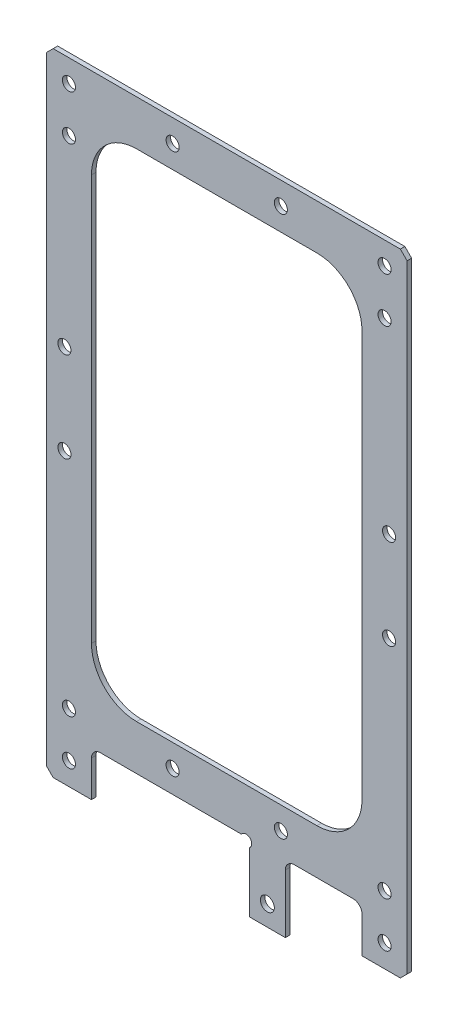
from build123d import *

# Parameters (mm, degrees)
BOSS_EXTRUDE12_DEPTH       = 1
SKETCH88_W                 = 60
SKETCH88_H                 = 110
CUT_EXTRUDE1_DEPTH         = 1
FILLET1_R                  = 10
M2_5_CLEARANCE_HOLE1_D     = 2.9
M2_5_CLEARANCE_HOLE1_DEPTH = 11.5
SKETCH91_W                 = 8
SKETCH91_H                 = 15
SKETCH91_R                 = 1.55
BOSS_EXTRUDE13_DEPTH       = 1
FILLET2_R                  = 2
CHAMFER1_SIZE              = 1.5
SKETCH93_R                 = 1.25
CUT_EXTRUDE2_DEPTH         = 10
M2_5_CLEARANCE_HOLE2_D     = 2.9
M2_5_CLEARANCE_HOLE2_DEPTH = 30


with BuildPart() as part:
    # Sketch87 → Boss-Extrude12 (new body)
    with BuildSketch(Plane.XY):
        Polygon((-40, 70), (-40, -70), (-30, -70), (-30, -60), (30, -60), (30, -70), (40, -70), (40, 70), align=None)
    extrude(amount=BOSS_EXTRUDE12_DEPTH)

    # Sketch88 → Cut-Extrude1 (cut)
    with BuildSketch(Plane.XY.offset(1)):
        with Locations((0, 5)):
            Rectangle(SKETCH88_W, SKETCH88_H)
    extrude(amount=-CUT_EXTRUDE1_DEPTH, mode=Mode.SUBTRACT)

    # Fillet1
    fillet1_edges = [part.edges().sort_by_distance(p)[0] for p in [
        (-30, -50, 0.5),
        (-30, 60, 0.5),
        (30, 60, 0.5),
        (30, -50, 0.5),
    ]]
    fillet(fillet1_edges, radius=FILLET1_R)

    # M2.5 Clearance Hole1
    with Locations(Plane(origin=(0, 0, 0), x_dir=(-1, 0, 0), z_dir=(0, 0, -1))):
        with Locations((35, -65), (35, -55), (-35, -55), (-35, -65), (12, -55), (-12, -55), (-12, 65), (12, 65), (-35, 65), (35, 65), (-35, 55), (35, 55)):
            Hole(M2_5_CLEARANCE_HOLE1_D / 2, depth=M2_5_CLEARANCE_HOLE1_DEPTH)

    # Sketch91 → Boss-Extrude13 (add)
    with BuildSketch(Plane(origin=(0, 0, 0), x_dir=(-1, 0, 0), z_dir=(0, 0, -1))):
        with Locations((-9, -67.5)):
            Rectangle(SKETCH91_W, SKETCH91_H)
        with Locations((-9, -70.5)):
            Circle(SKETCH91_R, mode=Mode.SUBTRACT)
    extrude(amount=-BOSS_EXTRUDE13_DEPTH)

    # Fillet2
    fillet2_edges = [part.edges().sort_by_distance(p)[0] for p in [
        (30, -60, 0.5),
        (-30, -60, 0.5),
        (13, -60, 0.5),
    ]]
    fillet(fillet2_edges, radius=FILLET2_R)

    # Chamfer1
    chamfer1_edges = [part.edges().sort_by_distance(p)[0] for p in [
        (40, 70, 0.5),
        (40, -70, 0.5),
        (-40, -70, 0.5),
        (-40, 70, 0.5),
    ]]
    chamfer(chamfer1_edges, length=CHAMFER1_SIZE)

    # Sketch93 → Cut-Extrude2 (cut)
    with BuildSketch(Plane(origin=(0, 0, 0), x_dir=(-1, 0, 0), z_dir=(0, 0, -1))):
        with Locations((-4.292893219, -60.707106781)):
            Circle(SKETCH93_R)
    extrude(amount=-CUT_EXTRUDE2_DEPTH, mode=Mode.SUBTRACT)

    # M2.5 Clearance Hole2
    with Locations(Plane(origin=(0, 0, 0), x_dir=(-1, 0, 0), z_dir=(0, 0, -1))):
        with Locations((-36, 14), (-36, -6)):
            m2_5_clearance_hole2 = Hole(M2_5_CLEARANCE_HOLE2_D / 2, depth=M2_5_CLEARANCE_HOLE2_DEPTH)

    # Mirror1: M2.5 Clearance Hole2 across plane
    add(m2_5_clearance_hole2.mirror(Plane(origin=(0, 0, 0), x_dir=(0, 0, 1), z_dir=(1, 0, 0))), mode=Mode.SUBTRACT)


solid = part.part
